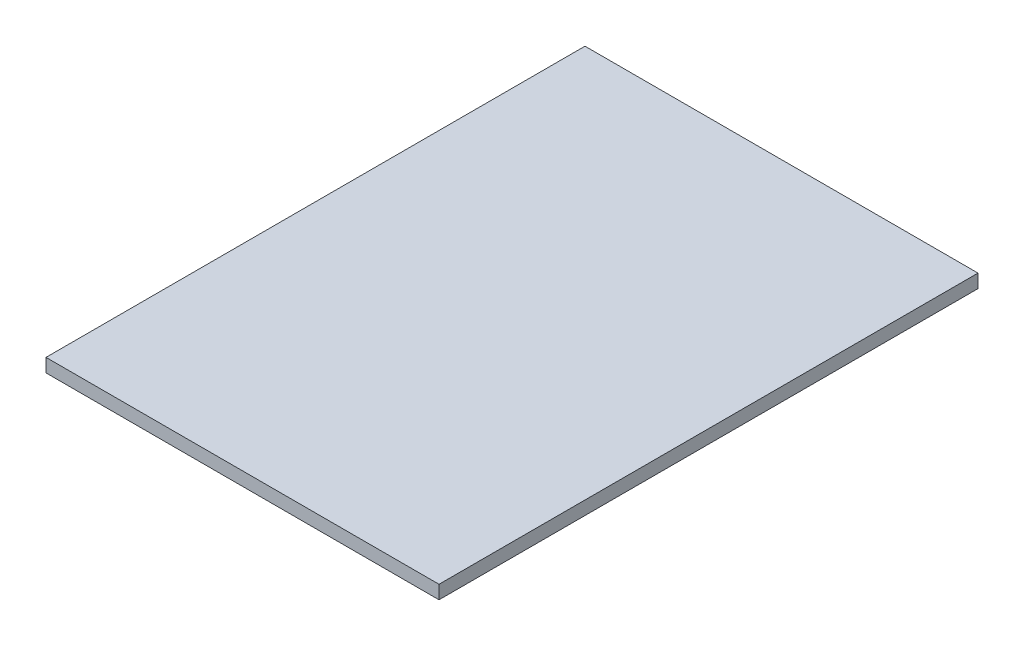
from build123d import *

# Parameters (mm, degrees)
SKETCH1_W           = 350
SKETCH1_H           = 480
BOSS_EXTRUDE1_DEPTH = 12


with BuildPart() as part:
    # Sketch1 → Boss-Extrude1 (new body)
    with BuildSketch(Plane(origin=(0, 0, 0), x_dir=(1, 0, 0), z_dir=(0, 1, 0))):
        with Locations((37.333333333, -2)):
            Rectangle(SKETCH1_W, SKETCH1_H)
    extrude(amount=BOSS_EXTRUDE1_DEPTH)


solid = part.part
